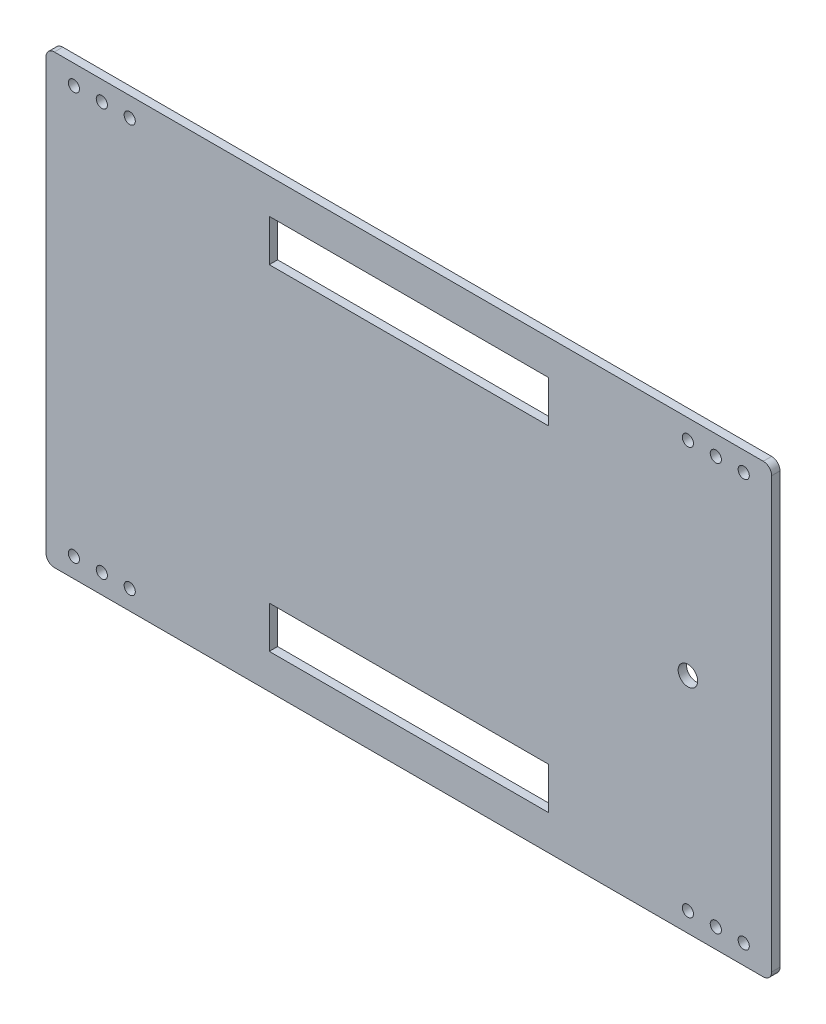
from build123d import *

# Parameters (mm, degrees)
MODEL_R             = 1.5
MODEL_R_2           = 2
MODEL_W             = 40
MODEL_H             = 40
MODEL_W_2           = 100
MODEL_H_2           = 15
EXTRUDE_1_DEPTH     = 3
SKETCH_2_W          = 96.919809602
SKETCH_2_H          = 88.226620572
EXTRUDE_2_DEPTH     = 3
SKETCH_3_W          = 55.118517674
SKETCH_3_H          = 61.40720761
EXTRUDE_3_DEPTH     = 3
SKETCH_4_R          = 3.5
CUT_EXTRUDE_4_DEPTH = 3
SKETCH_5_W          = 51.049365362
SKETCH_5_H          = 59.002708518
EXTRUDE_4_DEPTH     = 3


with BuildPart() as part:
    # Model → 凸台-拉伸1 (new body)
    with BuildSketch(Plane.XY):
        with BuildLine():
            Line((130, -77), (130, 77))
            ThreePointArc((130, 77), (129.121320344, 79.121320344), (127, 80))
            Line((127, 80), (-127, 80))
            ThreePointArc((-127, 80), (-129.121320344, 79.121320344), (-130, 77))
            Line((-130, 77), (-130, -77))
            ThreePointArc((-130, -77), (-129.121320344, -79.121320344), (-127, -80))
            Line((-127, -80), (127, -80))
            ThreePointArc((127, -80), (129.121320344, -79.121320344), (130, -77))
        make_face()
        with Locations((0, 40.4)):
            Circle(MODEL_R, mode=Mode.SUBTRACT)
        with Locations((40.4, 0)):
            Circle(MODEL_R, mode=Mode.SUBTRACT)
        with Locations((0, -40.4)):
            Circle(MODEL_R, mode=Mode.SUBTRACT)
        with Locations((-40.4, 0)):
            Circle(MODEL_R, mode=Mode.SUBTRACT)
        with Locations((-110, 73)):
            Circle(MODEL_R_2, mode=Mode.SUBTRACT)
        with Locations((110, 73)):
            Circle(MODEL_R_2, mode=Mode.SUBTRACT)
        with Locations((110, -73)):
            Circle(MODEL_R_2, mode=Mode.SUBTRACT)
        with Locations((-110, -73)):
            Circle(MODEL_R_2, mode=Mode.SUBTRACT)
        with Locations((-120, 73)):
            Circle(MODEL_R_2, mode=Mode.SUBTRACT)
        with Locations((120, 73)):
            Circle(MODEL_R_2, mode=Mode.SUBTRACT)
        with Locations((-120, -73)):
            Circle(MODEL_R_2, mode=Mode.SUBTRACT)
        with Locations((120, -73)):
            Circle(MODEL_R_2, mode=Mode.SUBTRACT)
        with Locations((-100, 73)):
            Circle(MODEL_R_2, mode=Mode.SUBTRACT)
        with Locations((100, 73)):
            Circle(MODEL_R_2, mode=Mode.SUBTRACT)
        with Locations((100, -73)):
            Circle(MODEL_R_2, mode=Mode.SUBTRACT)
        with Locations((-100, -73)):
            Circle(MODEL_R_2, mode=Mode.SUBTRACT)
        with Locations((-90, 0)):
            Rectangle(MODEL_W, MODEL_H, mode=Mode.SUBTRACT)
        with Locations((90, 0)):
            Rectangle(MODEL_W, MODEL_H, mode=Mode.SUBTRACT)
        with Locations((0, 60)):
            Rectangle(MODEL_W_2, MODEL_H_2, mode=Mode.SUBTRACT)
        with Locations((0, -60)):
            Rectangle(MODEL_W_2, MODEL_H_2, mode=Mode.SUBTRACT)
        with BuildLine():
            Line((28.543233286, -28.543233286), (28.543233286, -23.543233286))
            ThreePointArc((28.543233286, -23.543233286), (-26.162950904, 26.162950904), (23.543233286, -28.543233286))
            Line((23.543233286, -28.543233286), (28.543233286, -28.543233286))
        make_face(mode=Mode.SUBTRACT)
    extrude(amount=EXTRUDE_1_DEPTH)

    # 草图2 → 凸台-拉伸2 (add)
    with BuildSketch(Plane.XY.offset(3)):
        Rectangle(SKETCH_2_W, SKETCH_2_H)
    extrude(amount=-EXTRUDE_2_DEPTH)

    # 草图3 → 凸台-拉伸3 (add)
    with BuildSketch(Plane.XY.offset(3)):
        with Locations((88.781504979, -1.572172484)):
            Rectangle(SKETCH_3_W, SKETCH_3_H)
    extrude(amount=-EXTRUDE_3_DEPTH)

    # 草图4 → 切除-拉伸4 (cut)
    with BuildSketch(Plane.XY.offset(3)):
        with Locations((100, 0)):
            Circle(SKETCH_4_R)
    extrude(amount=-CUT_EXTRUDE_4_DEPTH, mode=Mode.SUBTRACT)

    # 草图5 → 凸台-拉伸4 (add)
    with BuildSketch(Plane.XY.offset(3)):
        with Locations((-90.446158197, 0)):
            Rectangle(SKETCH_5_W, SKETCH_5_H)
    extrude(amount=-EXTRUDE_4_DEPTH)


solid = part.part
